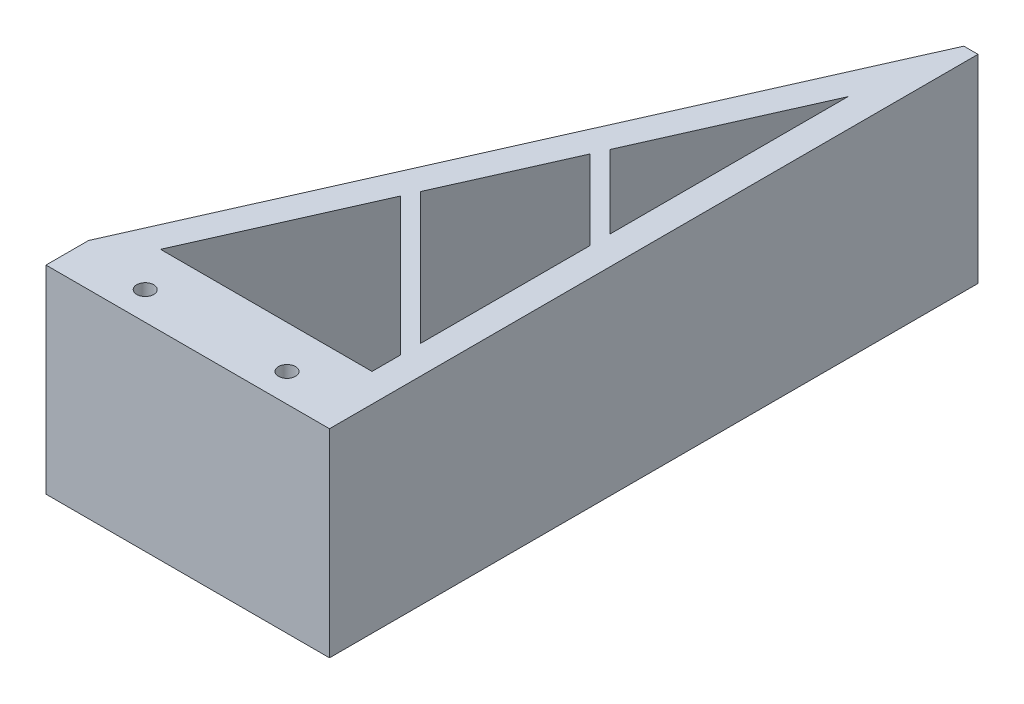
from build123d import *

# Parameters (mm, degrees)
BOSS_EXTRUDE1_DEPTH   = 14
BOSS_EXTRUDE1_2_DEPTH = 14
BOSS_EXTRUDE2_DEPTH   = 14
SKETCH3_R             = 0.6
CUT_EXTRUDE1_DEPTH    = 15


with BuildPart() as part:
    # Sketch2 → Boss-Extrude1 (new body)
    with BuildSketch(Plane(origin=(0, 0, 0), x_dir=(1, 0, 0), z_dir=(0, 1, 0))):
        Polygon((7.717934448, -19.134647491), (-1.99762589, -9.419087153), (-1.562483255, -8.440016225), (7.717934448, -17.720433929), align=None)
    extrude(amount=BOSS_EXTRUDE1_DEPTH)



with BuildPart() as body_2:
    # Sketch2 → Boss-Extrude1 2 (new body)
    with BuildSketch(Plane(origin=(0, 0, 0), x_dir=(1, 0, 0), z_dir=(0, 1, 0))):
        Polygon((7.717934448, -5.761075504), (2.117319337, -0.160460393), (2.552461971, 0.818610535), (7.717934448, -4.346861942), align=None)
    extrude(amount=BOSS_EXTRUDE1_2_DEPTH)


with BuildPart() as part_1:
    add(part.part)

    add(body_2.part)  # Boss-Extrude2 merges body 2
    # Sketch1 → Boss-Extrude2 (add)
    with BuildSketch(Plane(origin=(0, 0, 0), x_dir=(1, 0, 0), z_dir=(0, 1, 0))):
        Polygon((-10.282065552, -23.134647491), (8.717934448, 19.615352509), (9.717934448, 19.615352509), (9.717934448, -23.134647491), (9.717934448, -26.134647491), (-10.282065552, -26.134647491), align=None)
        Polygon((7.717934448, -21.134647491), (7.717934448, 12.440923608), (-7.204541596, -21.134647491), align=None, mode=Mode.SUBTRACT)
    extrude(amount=BOSS_EXTRUDE2_DEPTH)

    # Sketch3 → Cut-Extrude1 (cut, through all)
    with BuildSketch(Plane(origin=(0, 14, 0), x_dir=(1, 0, 0), z_dir=(0, 1, 0))):
        with Locations((4.717934448, -24.134647491)):
            Circle(SKETCH3_R)
        with Locations((-5.282065552, -24.134647491)):
            Circle(SKETCH3_R)
    extrude(amount=-CUT_EXTRUDE1_DEPTH, mode=Mode.SUBTRACT)


solid = part_1.part
